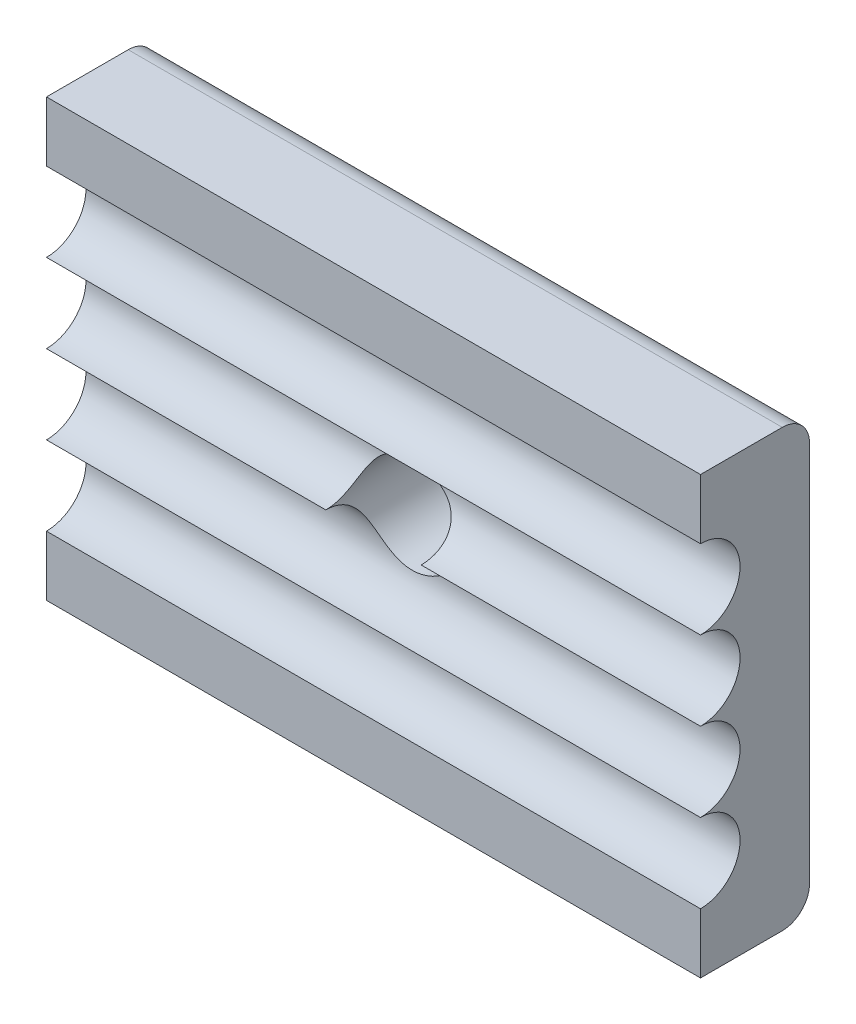
from build123d import *

# Parameters (mm, degrees)
SKETCH2_W           = 24
SKETCH2_H           = 16
BOSS_EXTRUDE1_DEPTH = 4
SKETCH3_R           = 1.75
CUT_EXTRUDE1_DEPTH  = 5
FILLET1_R           = 1
CUT_EXTRUDE2_DEPTH  = 29


with BuildPart() as part:
    # Sketch2 → Boss-Extrude1 (new body)
    with BuildSketch(Plane.XY):
        with Locations((6.957345972, -4)):
            Rectangle(SKETCH2_W, SKETCH2_H)
    extrude(amount=BOSS_EXTRUDE1_DEPTH)

    # Sketch3 → Cut-Extrude1 (cut)
    with BuildSketch(Plane.XY.offset(4)):
        with Locations((6.957345972, -4)):
            Circle(SKETCH3_R)
    extrude(amount=-CUT_EXTRUDE1_DEPTH, mode=Mode.SUBTRACT)

    # Fillet1
    fillet1_edges = [part.edges().sort_by_distance(p)[0] for p in [
        (6.957345972, 4, 0),
        (6.957345972, -12, 0),
    ]]
    fillet(fillet1_edges, radius=FILLET1_R)

    # Sketch4 → Cut-Extrude2 (cut)
    with BuildSketch(Plane.ZY.offset(5.042654028)):
        with BuildLine():
            ThreePointArc((5.45, -8.35), (5.025304833, -7.324695167), (4, -6.9))
            Line((4, -6.9), (4, -9.8))
            ThreePointArc((4, -9.8), (5.025304833, -9.375304833), (5.45, -8.35))
        make_face()
        with BuildLine():
            Line((4, -9.8), (4, -6.9))
            ThreePointArc((4, -6.9), (2.55, -8.35), (4, -9.8))
        make_face()
        with BuildLine():
            ThreePointArc((4, -6.9), (5.025304833, -6.475304833), (5.45, -5.45))
            ThreePointArc((5.45, -5.45), (5.025304832, -4.424695167), (3.999999999, -4))
            Line((4, -4), (4, -6.9))
        make_face()
        with BuildLine():
            Line((4, -6.9), (4, -4))
            ThreePointArc((3.999999999, -4), (2.55, -5.450000001), (4, -6.9))
        make_face()
        with BuildLine():
            ThreePointArc((4, -1.1), (2.55, -2.549999999), (3.999999999, -4))
            Line((4, -4), (4, -1.1))
        make_face()
        with BuildLine():
            Line((4, -1.1), (4, -4))
            ThreePointArc((3.999999999, -4), (5.025304832, -3.575304833), (5.45, -2.55))
            ThreePointArc((5.45, -2.55), (5.025304833, -1.524695167), (4, -1.1))
        make_face()
        with BuildLine():
            ThreePointArc((4, 1.8), (2.55, 0.35), (4, -1.1))
            Line((4, -1.1), (4, 1.8))
        make_face()
        with BuildLine():
            Line((4, 1.8), (4, -1.1))
            ThreePointArc((4, -1.1), (5.025304833, -0.675304833), (5.45, 0.35))
            ThreePointArc((5.45, 0.35), (5.025304833, 1.375304833), (4, 1.8))
        make_face()
    extrude(amount=-CUT_EXTRUDE2_DEPTH, mode=Mode.SUBTRACT)


solid = part.part
